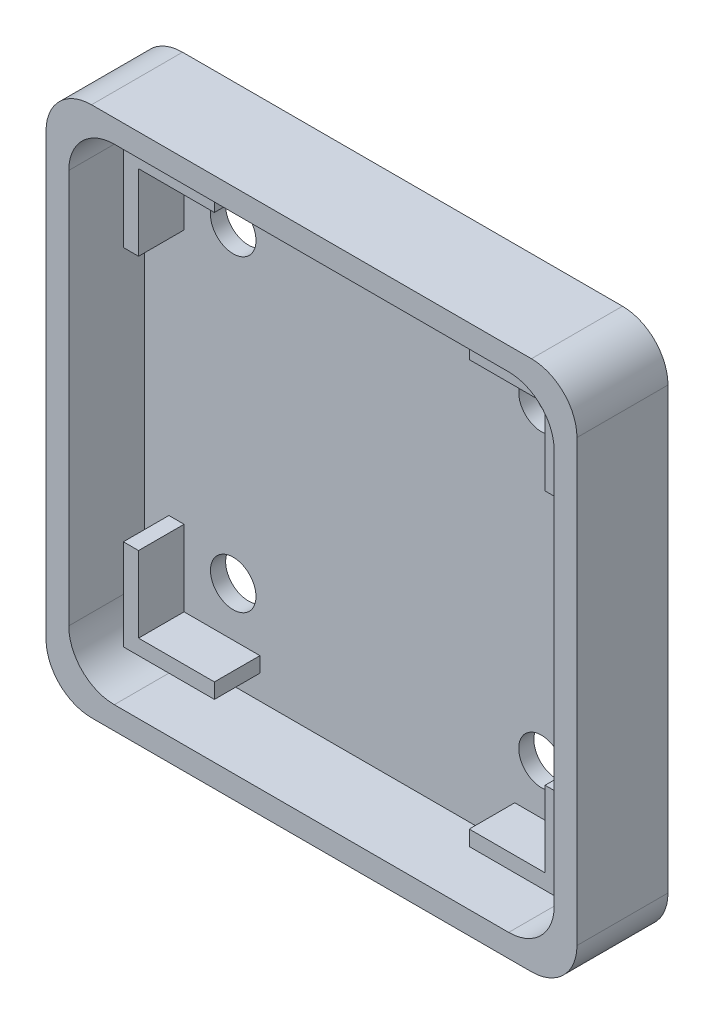
from build123d import *

# Parameters (mm, degrees)
BOSS_EXTRUDE1_DEPTH = 10
CUT_EXTRUDE1_DEPTH  = 9
SKETCH5_R           = 1.5
CUT_EXTRUDE2_DEPTH  = 2
BOSS_EXTRUDE2_DEPTH = 3
SKETCH7_R           = 24.910226266
CUT_EXTRUDE5_DEPTH  = 4


with BuildPart() as part:
    # Sketch1 → Boss-Extrude1 (new body)
    with BuildSketch(Plane.XY):
        with BuildLine():
            Line((3, 0), (32, 0))
            ThreePointArc((32, 0), (34.121320344, -0.878679656), (35, -3))
            Line((35, -3), (35, -32))
            ThreePointArc((35, -32), (34.121320344, -34.121320344), (32, -35))
            Line((32, -35), (3, -35))
            ThreePointArc((3, -35), (0.878679656, -34.121320344), (0, -32))
            Line((0, -32), (0, -3))
            ThreePointArc((0, -3), (0.878679656, -0.878679656), (3, 0))
        make_face()
    extrude(amount=BOSS_EXTRUDE1_DEPTH)

    # Sketch2 → Cut-Extrude1 (cut)
    with BuildSketch(Plane.XY.offset(10)):
        with BuildLine():
            Line((1.5, -4.5), (1.5, -30.5))
            ThreePointArc((1.5, -30.5), (2.378679656, -32.621320344), (4.5, -33.5))
            Line((4.5, -33.5), (30.5, -33.5))
            ThreePointArc((30.5, -33.5), (32.621320344, -32.621320344), (33.5, -30.5))
            Line((33.5, -30.5), (33.5, -4.5))
            ThreePointArc((33.5, -4.5), (32.621320344, -2.378679656), (30.5, -1.5))
            Line((30.5, -1.5), (4.5, -1.5))
            ThreePointArc((4.5, -1.5), (2.378679656, -2.378679656), (1.5, -4.5))
        make_face()
    extrude(amount=-CUT_EXTRUDE1_DEPTH, mode=Mode.SUBTRACT)

    # Sketch5 → Cut-Extrude2 (cut, through all)
    with BuildSketch(Plane.XY.offset(1)):
        with Locations((7.34, -7.34)):
            Circle(SKETCH5_R)
        with Locations((7.34, -27.66)):
            Circle(SKETCH5_R)
        with Locations((27.66, -27.66)):
            Circle(SKETCH5_R)
        with Locations((27.66, -7.34)):
            Circle(SKETCH5_R)
    extrude(amount=-CUT_EXTRUDE2_DEPTH, mode=Mode.SUBTRACT)

    # Sketch3 → Boss-Extrude2 (add)
    with BuildSketch(Plane.XY.offset(1)):
        Polygon((3.1, -3.1), (3.1, -9.1), (4.1, -9.1), (4.1, -4.1), (9.1, -4.1), (9.1, -3.1), align=None)
        Polygon((30.9, -9.1), (31.9, -9.1), (31.9, -3.1), (25.9, -3.1), (25.9, -4.1), (30.9, -4.1), align=None)
        Polygon((25.9, -30.9), (25.9, -31.9), (31.9, -31.9), (31.9, -25.9), (30.9, -25.9), (30.9, -30.9), align=None)
        Polygon((3.1, -25.9), (3.1, -31.9), (9.1, -31.9), (9.1, -30.9), (4.1, -30.9), (4.1, -25.9), align=None)
    extrude(amount=BOSS_EXTRUDE2_DEPTH)

    # Sketch7 → Cut-Extrude5 (cut)
    with BuildSketch(Plane.XY.offset(10)):
        with Locations((16.498966125, -17.5)):
            Circle(SKETCH7_R)
    extrude(amount=-CUT_EXTRUDE5_DEPTH, mode=Mode.SUBTRACT)


solid = part.part
